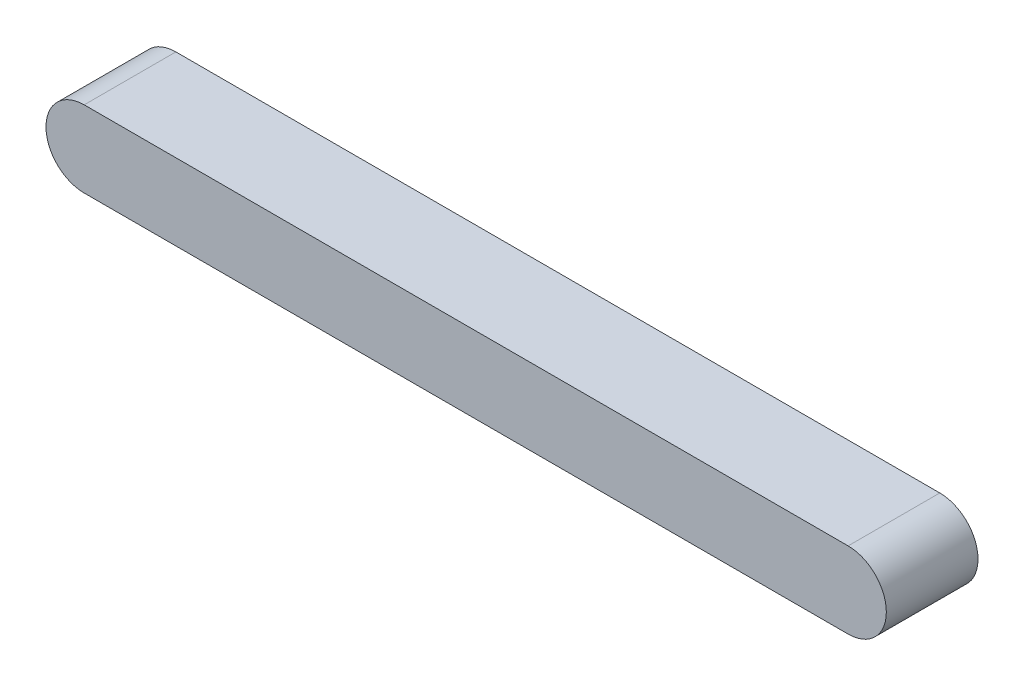
from build123d import *

# Parameters (mm, degrees)
EXTRUDE_1_DEPTH = 12


with BuildPart() as part:
    # 草图1 → 凸台-拉伸1 (new body)
    with BuildSketch(Plane.XY):
        with BuildLine():
            Line((-50, 5), (50, 5))
            ThreePointArc((50, 5), (55, 0), (50, -5))
            Line((50, -5), (-50, -5))
            ThreePointArc((-50, -5), (-55, 0), (-50, 5))
        make_face()
    extrude(amount=EXTRUDE_1_DEPTH)


solid = part.part
